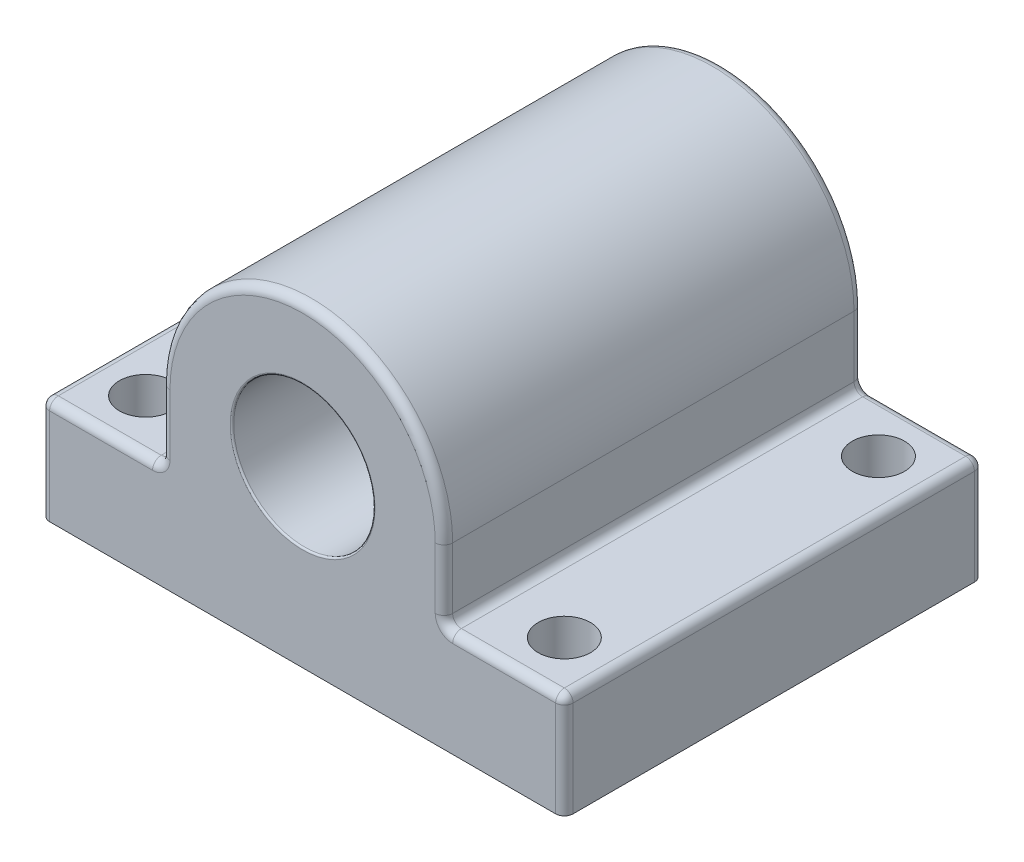
from build123d import *

# Parameters (mm, degrees)
CROQUIS1_R              = 4.05
SALIENTE_EXTRUIR1_DEPTH = 12
CORTAR_EXTRUIR1_REACH   = 8
CROQUIS2_R              = 1.5
REDONDEO1_R             = 0.5
REDONDEO2_R             = 0.1


with BuildPart() as part:
    # Croquis1 → Saliente-Extruir1 (new body, symmetric)
    with BuildSketch(Plane.XY):
        with BuildLine():
            Line((15, 0), (-15, 0))
            Line((-15, 0), (-15, 6))
            Line((-15, 6), (-8.1, 6))
            Line((-8.1, 6), (-8.1, 10))
            ThreePointArc((-8.1, 10), (0, 18.1), (8.1, 10))
            Line((8.1, 10), (8.1, 6))
            Line((8.1, 6), (15, 6))
            Line((15, 6), (15, 0))
        make_face()
        with Locations((0, 10)):
            Circle(CROQUIS1_R, mode=Mode.SUBTRACT)
    extrude(amount=SALIENTE_EXTRUIR1_DEPTH, both=True)

    # Croquis2 → Cortar-Extruir1 (cut, up to next)
    with BuildSketch(Plane(origin=(0, 6, 0), x_dir=(1, 0, 0), z_dir=(0, 1, 0)), mode=Mode.PRIVATE) as cortar_extruir1_sk1:
        with Locations((-12, 9)):
            Circle(CROQUIS2_R)
    cortar_extruir1_tool1 = extrude(cortar_extruir1_sk1.sketch, amount=-CORTAR_EXTRUIR1_REACH, mode=Mode.PRIVATE) & part.part
    add(cortar_extruir1_tool1.solids().sort_by_distance((-12, 6, -9))[0], mode=Mode.SUBTRACT)
    # Croquis2 → Cortar-Extruir1 (cut, up to next)
    with BuildSketch(Plane(origin=(0, 6, 0), x_dir=(1, 0, 0), z_dir=(0, 1, 0)), mode=Mode.PRIVATE) as cortar_extruir1_sk2:
        with Locations((12, 9)):
            Circle(CROQUIS2_R)
    cortar_extruir1_tool2 = extrude(cortar_extruir1_sk2.sketch, amount=-CORTAR_EXTRUIR1_REACH, mode=Mode.PRIVATE) & part.part
    add(cortar_extruir1_tool2.solids().sort_by_distance((12, 6, -9))[0], mode=Mode.SUBTRACT)
    # Croquis2 → Cortar-Extruir1 (cut, up to next)
    with BuildSketch(Plane(origin=(0, 6, 0), x_dir=(1, 0, 0), z_dir=(0, 1, 0)), mode=Mode.PRIVATE) as cortar_extruir1_sk3:
        with Locations((-12, -9)):
            Circle(CROQUIS2_R)
    cortar_extruir1_tool3 = extrude(cortar_extruir1_sk3.sketch, amount=-CORTAR_EXTRUIR1_REACH, mode=Mode.PRIVATE) & part.part
    add(cortar_extruir1_tool3.solids().sort_by_distance((-12, 6, 9))[0], mode=Mode.SUBTRACT)
    # Croquis2 → Cortar-Extruir1 (cut, up to next)
    with BuildSketch(Plane(origin=(0, 6, 0), x_dir=(1, 0, 0), z_dir=(0, 1, 0)), mode=Mode.PRIVATE) as cortar_extruir1_sk4:
        with Locations((12, -9)):
            Circle(CROQUIS2_R)
    cortar_extruir1_tool4 = extrude(cortar_extruir1_sk4.sketch, amount=-CORTAR_EXTRUIR1_REACH, mode=Mode.PRIVATE) & part.part
    add(cortar_extruir1_tool4.solids().sort_by_distance((12, 6, 9))[0], mode=Mode.SUBTRACT)

    # Redondeo1
    redondeo1_edges = [part.edges().sort_by_distance(p)[0] for p in [
        (8.1, 8, -12),
        (11.55, 6, 12),
        (15, 3, 12),
        (-15, 3, 12),
        (-11.55, 6, 12),
        (-8.1, 8, 12),
        (0, 18.1, 12),
        (8.1, 8, 12),
        (0, 18.1, -12),
        (8.1, 6, 0),
        (15, 6, 0),
        (-15, 6, 0),
        (-8.1, 6, 0),
        (-8.1, 8, -12),
        (-11.55, 6, -12),
        (-15, 3, -12),
        (15, 3, -12),
        (11.55, 6, -12),
    ]]
    fillet(redondeo1_edges, radius=REDONDEO1_R)

    # Redondeo2
    redondeo2_edges = [part.edges().sort_by_distance(p)[0] for p in [
        (-4.05, 10, 12),
        (-4.05, 10, -12),
    ]]
    fillet(redondeo2_edges, radius=REDONDEO2_R)


solid = part.part
